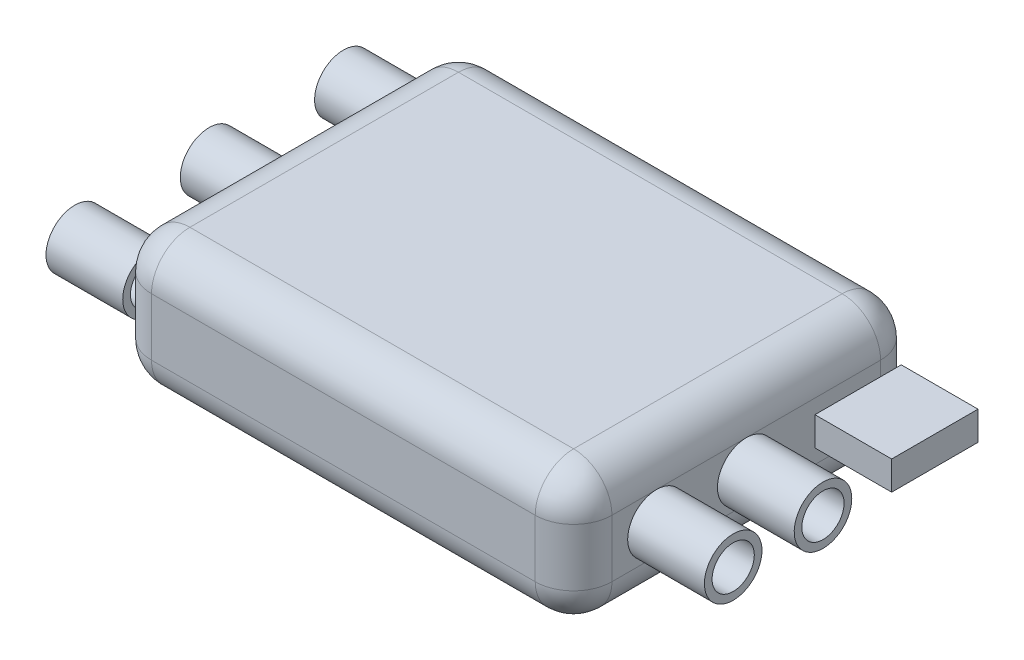
from build123d import *

# Parameters (mm, degrees)
BOSS_EXTRUDE1_DEPTH = 7
FILLET1_R           = 2
SKETCH3_R           = 1.5
SKETCH3_R_2         = 1.1
BOSS_EXTRUDE2_DEPTH = 4
SKETCH4_R           = 1.5
SKETCH4_R_2         = 1.1
SKETCH4_W           = 4.5
SKETCH4_H           = 1.5
BOSS_EXTRUDE3_DEPTH = 4


with BuildPart() as part:
    # Sketch1 → Boss-Extrude1 (new body)
    with BuildSketch(Plane(origin=(0, 0, 0), x_dir=(1, 0, 0), z_dir=(0, 1, 0))):
        with BuildLine():
            Line((10, -9), (-10, -9))
            ThreePointArc((-10, -9), (-11.414213562, -8.414213562), (-12, -7))
            Line((-12, -7), (-12, 7))
            ThreePointArc((-12, 7), (-11.414213562, 8.414213562), (-10, 9))
            Line((-10, 9), (10, 9))
            ThreePointArc((10, 9), (11.414213562, 8.414213562), (12, 7))
            Line((12, 7), (12, -7))
            ThreePointArc((12, -7), (11.414213562, -8.414213562), (10, -9))
        make_face()
    extrude(amount=BOSS_EXTRUDE1_DEPTH)

    # Fillet1
    fillet1_edges = [part.edges().sort_by_distance(p)[0] for p in [
        (12, 0, 0),
        (11.414213562, 0, 8.414213562),
        (0, 0, 9),
        (-11.414213562, 0, 8.414213562),
        (11.414213562, 7, 8.414213562),
        (12, 7, 0),
        (11.414213562, 7, -8.414213562),
        (0, 7, -9),
        (-11.414213562, 7, -8.414213562),
        (-12, 7, 0),
        (-11.414213562, 7, 8.414213562),
        (-12, 0, 0),
        (0, 7, 9),
        (-11.414213562, 0, -8.414213562),
        (0, 0, -9),
        (11.414213562, 0, -8.414213562),
    ]]
    fillet(fillet1_edges, radius=FILLET1_R)

    # Sketch3 → Boss-Extrude2 (add)
    with BuildSketch(Plane.ZY.offset(12)):
        with Locations((7, 3.5)):
            Circle(SKETCH3_R)
        with Locations((7, 3.5)):
            Circle(SKETCH3_R_2, mode=Mode.SUBTRACT)
        with Locations((0, 3.5)):
            Circle(SKETCH3_R)
        with Locations((0, 3.5)):
            Circle(SKETCH3_R_2, mode=Mode.SUBTRACT)
        with Locations((-7, 3.5)):
            Circle(SKETCH3_R)
        with Locations((-7, 3.5)):
            Circle(SKETCH3_R_2, mode=Mode.SUBTRACT)
    extrude(amount=BOSS_EXTRUDE2_DEPTH)

    # Sketch4 → Boss-Extrude3 (add)
    with BuildSketch(Plane(origin=(12, 0, 0), x_dir=(0, 0, -1), z_dir=(1, 0, 0))):
        with Locations((-4.680368176, 3.5)):
            Circle(SKETCH4_R)
        with Locations((-4.680368176, 3.5)):
            Circle(SKETCH4_R_2, mode=Mode.SUBTRACT)
        with Locations((0, 3.5)):
            Circle(SKETCH4_R)
        with Locations((0, 3.5)):
            Circle(SKETCH4_R_2, mode=Mode.SUBTRACT)
        with Locations((5.830286219, 3.5)):
            Rectangle(SKETCH4_W, SKETCH4_H)
    extrude(amount=BOSS_EXTRUDE3_DEPTH)


solid = part.part
